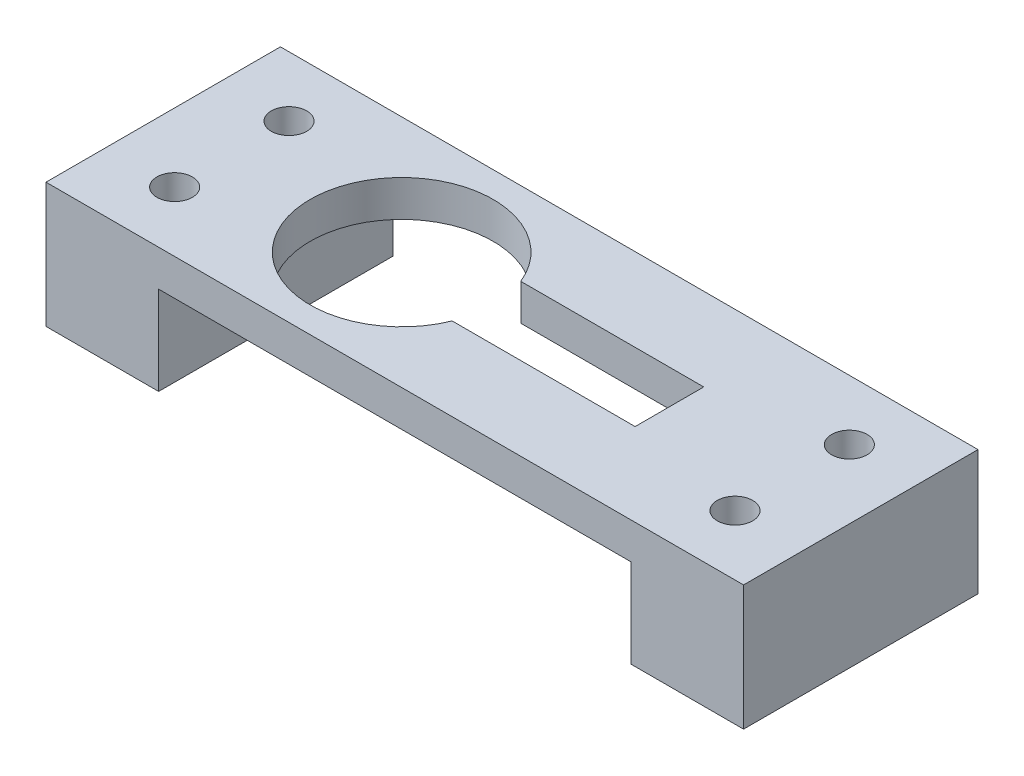
from build123d import *

# Parameters (mm, degrees)
SKETCH2_W           = 61
SKETCH2_H           = 20.5
SKETCH2_R           = 1.55
BOSS_EXTRUDE1_DEPTH = 3.175
SKETCH3_W           = 9.85
SKETCH3_H           = 20.5
SKETCH3_R           = 1.55
BOSS_EXTRUDE2_DEPTH = 7.75


with BuildPart() as part:
    # Sketch2 → Boss-Extrude1 (new body)
    with BuildSketch(Plane(origin=(0, 0, 0), x_dir=(1, 0, 0), z_dir=(0, 1, 0))):
        Rectangle(SKETCH2_W, SKETCH2_H)
        with Locations((-24.5, -5)):
            Circle(SKETCH2_R, mode=Mode.SUBTRACT)
        with BuildLine():
            ThreePointArc((-2.233801513, -3), (-17.65, 0), (-2.233801513, 3))
            Line((-2.233801513, 3), (13.766198487, 3))
            Line((13.766198487, 3), (13.766198487, -3))
            Line((13.766198487, -3), (-2.233801513, -3))
        make_face(mode=Mode.SUBTRACT)
        with Locations((24.5, -5)):
            Circle(SKETCH2_R, mode=Mode.SUBTRACT)
        with Locations((-24.5, 5)):
            Circle(SKETCH2_R, mode=Mode.SUBTRACT)
        with Locations((24.5, 5)):
            Circle(SKETCH2_R, mode=Mode.SUBTRACT)
    extrude(amount=BOSS_EXTRUDE1_DEPTH)

    # Sketch3 → Boss-Extrude2 (add)
    with BuildSketch(Plane.XZ):
        with Locations((-25.575, 0)):
            Rectangle(SKETCH3_W, SKETCH3_H)
        with Locations((-24.5, -5)):
            Circle(SKETCH3_R, mode=Mode.SUBTRACT)
        with Locations((-24.5, 5)):
            Circle(SKETCH3_R, mode=Mode.SUBTRACT)
        with Locations((25.575, 0)):
            Rectangle(SKETCH3_W, SKETCH3_H)
        with Locations((24.5, -5)):
            Circle(SKETCH3_R, mode=Mode.SUBTRACT)
        with Locations((24.5, 5)):
            Circle(SKETCH3_R, mode=Mode.SUBTRACT)
    extrude(amount=BOSS_EXTRUDE2_DEPTH)


solid = part.part
